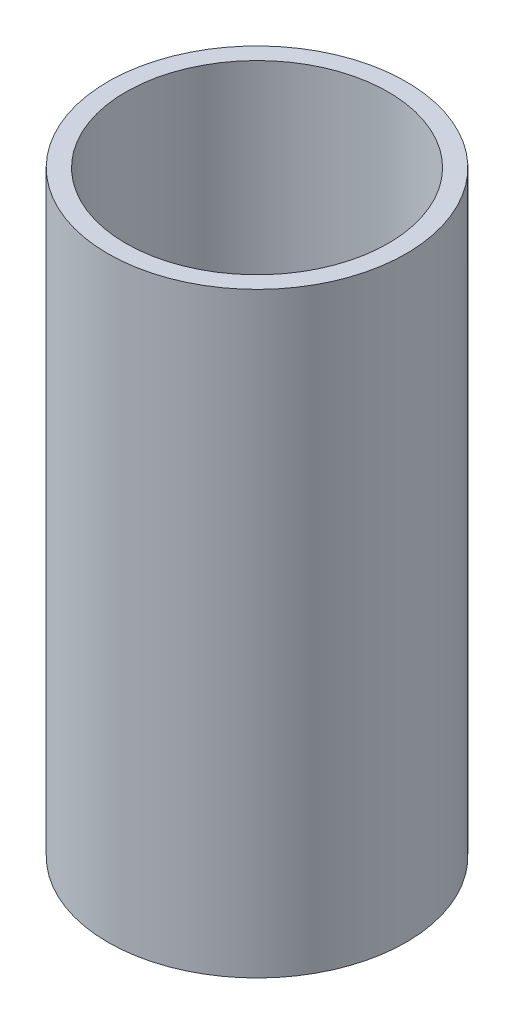
from build123d import *

# Parameters (mm, degrees)
SKETCH1_R           = 12.7
SKETCH1_R_2         = 11.176
BOSS_EXTRUDE1_DEPTH = 50.8


with BuildPart() as part:
    # Sketch1 → Boss-Extrude1 (new body)
    with BuildSketch(Plane(origin=(0, 0, 0), x_dir=(1, 0, 0), z_dir=(0, 1, 0))):
        Circle(SKETCH1_R)
        Circle(SKETCH1_R_2, mode=Mode.SUBTRACT)
    extrude(amount=BOSS_EXTRUDE1_DEPTH)


solid = part.part
